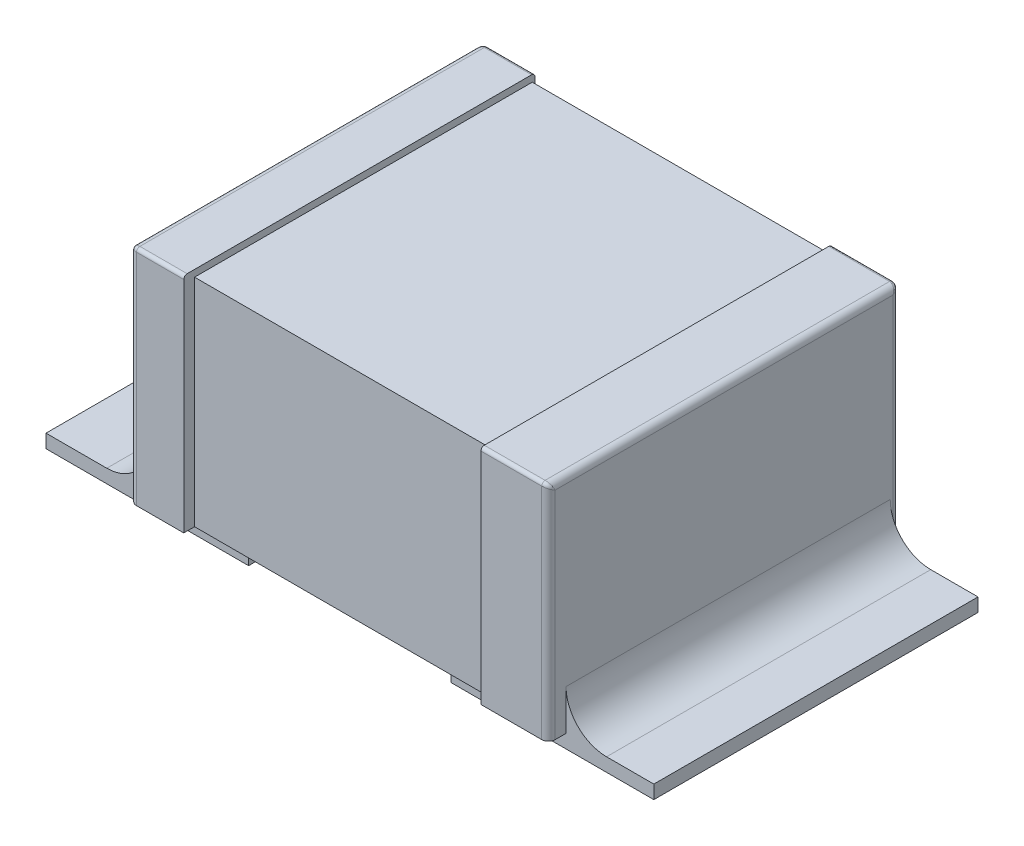
from build123d import *

# Parameters (mm, degrees)
SKETCH1_W           = 2.5
SKETCH1_H           = 1.6
BOSS_EXTRUDE1_DEPTH = 1.1
BOSS_EXTRUDE2_DEPTH = 0.5
BOSS_EXTRUDE3_DEPTH = 0.4
SKETCH6_W           = 1.5
SKETCH6_H           = 2.4
BOSS_EXTRUDE4_DEPTH = 0.1
FILLET3_R           = 0.05
FILLET4_R           = 0.3


with BuildPart() as part:
    # Sketch1 → Boss-Extrude1 (new, symmetric)
    with BuildSketch(Plane(origin=(0, 0, 0), x_dir=(0, 0, -1), z_dir=(1, 0, 0))):
        with Locations((0, 0.9)):
            Rectangle(SKETCH1_W, SKETCH1_H)
    extrude(amount=BOSS_EXTRUDE1_DEPTH, both=True)

    # Sketch3 → Boss-Extrude2 (add)
    with BuildSketch(Plane(origin=(1.1, 0, 0), x_dir=(0, 0, -1), z_dir=(1, 0, 0))):
        with BuildLine():
            Line((-1.305, 1.75), (1.245, 1.75))
            ThreePointArc((1.245, 1.75), (1.26267767, 1.74267767), (1.27, 1.725))
            Line((1.27, 1.725), (1.27, 0.1))
            Line((1.27, 0.1), (-1.33, 0.1))
            Line((-1.33, 0.1), (-1.33, 1.725))
            ThreePointArc((-1.33, 1.725), (-1.32267767, 1.74267767), (-1.305, 1.75))
        make_face()
    extrude(amount=BOSS_EXTRUDE2_DEPTH)

    # Sketch5 → Boss-Extrude3 (add)
    with BuildSketch(Plane.ZY.offset(1.1)):
        with BuildLine():
            Line((-1.245, 1.75), (1.305, 1.75))
            ThreePointArc((1.305, 1.75), (1.32267767, 1.74267767), (1.33, 1.725))
            Line((1.33, 1.725), (1.33, 0.1))
            Line((1.33, 0.1), (-1.27, 0.1))
            Line((-1.27, 0.1), (-1.27, 1.725))
            ThreePointArc((-1.27, 1.725), (-1.26267767, 1.74267767), (-1.245, 1.75))
        make_face()
    extrude(amount=BOSS_EXTRUDE3_DEPTH)

    # Sketch6 → Boss-Extrude4 (add)
    with BuildSketch(Plane(origin=(0, 0, 0), x_dir=(1, 0, 0), z_dir=(0, 1, 0))):
        with Locations((-1.5, 0)):
            Rectangle(SKETCH6_W, SKETCH6_H)
        with Locations((1.5, 0)):
            Rectangle(SKETCH6_W, SKETCH6_H)
    extrude(amount=BOSS_EXTRUDE4_DEPTH)

    # Fillet3
    fillet3_edges = [part.edges().sort_by_distance(p)[0] for p in [
        (1.6, 0.9125, -1.27),
        (1.6, 1.74267767, -1.26267767),
        (1.6, 1.75, 0.03),
        (1.6, 1.74267767, 1.32267767),
        (1.6, 0.9125, 1.33),
        (-1.5, 0.9125, 1.33),
        (-1.5, 1.74267767, 1.32267767),
        (-1.5, 1.75, 0.03),
        (-1.5, 1.74267767, -1.26267767),
        (-1.5, 0.9125, -1.27),
    ]]
    fillet(fillet3_edges, radius=FILLET3_R)

    # Fillet4
    fillet4_edges = [part.edges().sort_by_distance(p)[0] for p in [
        (-1.5, 0.1, 0),
        (1.6, 0.1, 0),
    ]]
    fillet(fillet4_edges, radius=FILLET4_R)


solid = part.part
